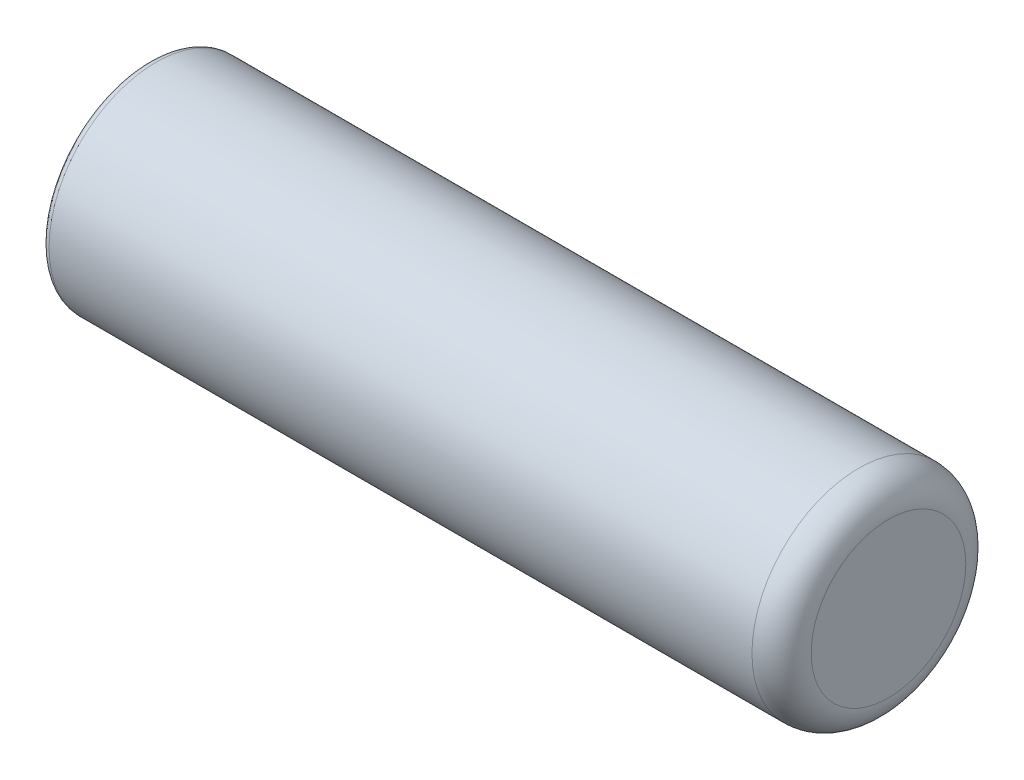
from build123d import *

# Parameters (mm, degrees)
SKETCH1_R           = 14.45
BOSS_EXTRUDE1_DEPTH = 100
FILLET1_R           = 4
SKETCH3_R           = 11
CUT_EXTRUDE1_DEPTH  = 80
FILLET2_R           = 1


with BuildPart() as part:
    # Sketch1 → Boss-Extrude1 (new body)
    with BuildSketch(Plane(origin=(0, 0, 0), x_dir=(0, 0, -1), z_dir=(1, 0, 0))):
        Circle(SKETCH1_R)
    extrude(amount=BOSS_EXTRUDE1_DEPTH)

    # Fillet1
    fillet1_edges = [part.edges().sort_by_distance(p)[0] for p in [
        (100, 0, 14.45),
    ]]
    fillet(fillet1_edges, radius=FILLET1_R)

    # Sketch3 → Cut-Extrude1 (cut)
    with BuildSketch(Plane.ZY):
        Circle(SKETCH3_R)
    extrude(amount=-CUT_EXTRUDE1_DEPTH, mode=Mode.SUBTRACT)

    # Fillet2
    fillet2_edges = [part.edges().sort_by_distance(p)[0] for p in [
        (0, 0, 14.45),
    ]]
    fillet(fillet2_edges, radius=FILLET2_R)


solid = part.part
